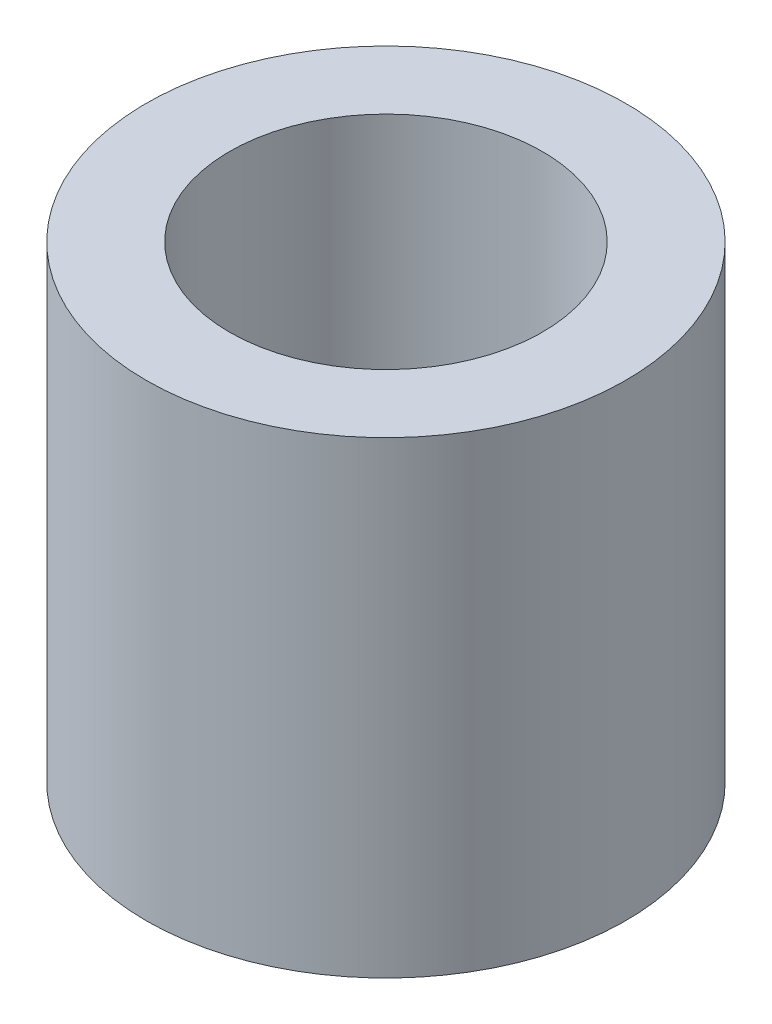
from build123d import *

# Parameters (mm, degrees)
SKETCH1_R           = 4.1
SKETCH1_R_2         = 2.675
BOSS_EXTRUDE1_DEPTH = 8


with BuildPart() as part:
    # Sketch1 → Boss-Extrude1 (new body)
    with BuildSketch(Plane(origin=(0, 0, 0), x_dir=(1, 0, 0), z_dir=(0, 1, 0))):
        Circle(SKETCH1_R)
        Circle(SKETCH1_R_2, mode=Mode.SUBTRACT)
    extrude(amount=BOSS_EXTRUDE1_DEPTH)


solid = part.part
